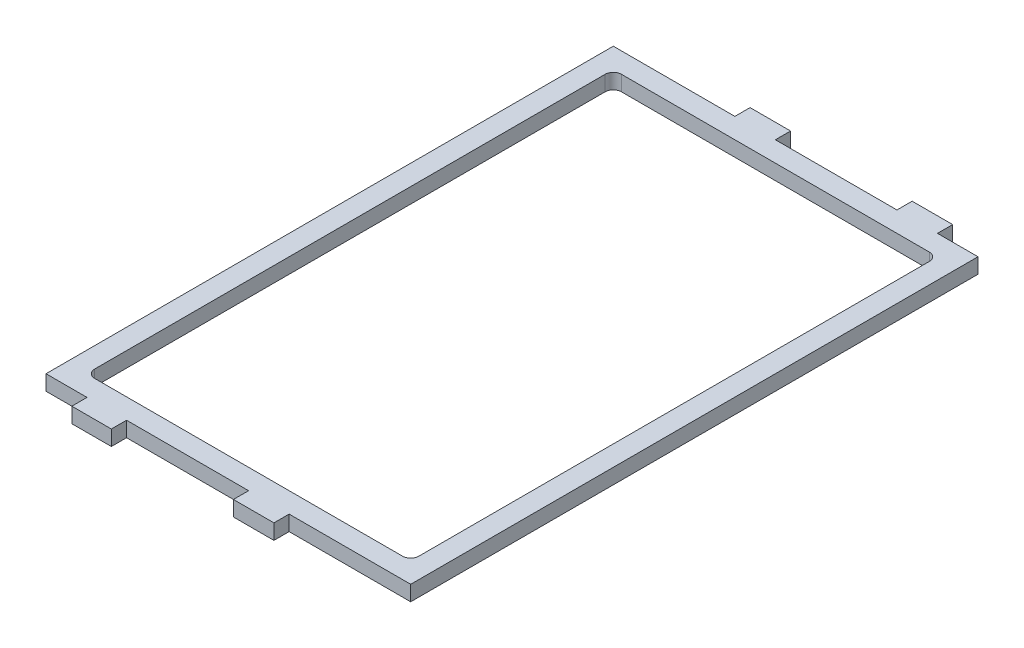
from build123d import *

# Parameters (mm, degrees)
SKETCH1_W           = 114.3
SKETCH1_H           = 177.8
SKETCH1_W_2         = 101.6
SKETCH1_H_2         = 165.1
BOSS_EXTRUDE1_DEPTH = 4.7625
SKETCH2_W           = 12.38677804
SKETCH2_H           = 4.7625
SKETCH2_W_2         = 12.7
BOSS_EXTRUDE2_DEPTH = 4.7625
SKETCH3_W           = 12.7
SKETCH3_H           = 4.7625
BOSS_EXTRUDE3_DEPTH = 4.7625
FILLET1_R           = 2.54


with BuildPart() as part:
    # Sketch1 → Boss-Extrude1 (new body)
    with BuildSketch(Plane(origin=(0, 0, 0), x_dir=(1, 0, 0), z_dir=(0, 1, 0))):
        Rectangle(SKETCH1_W, SKETCH1_H)
        Rectangle(SKETCH1_W_2, SKETCH1_H_2, mode=Mode.SUBTRACT)
    extrude(amount=BOSS_EXTRUDE1_DEPTH)

    # Sketch2 → Boss-Extrude2 (add)
    with BuildSketch(Plane.XY.offset(88.9)):
        with Locations((-38.1, 2.38125)):
            Rectangle(SKETCH2_W, SKETCH2_H)
        with Locations((12.7, 2.38125)):
            Rectangle(SKETCH2_W_2, SKETCH2_H)
    extrude(amount=BOSS_EXTRUDE2_DEPTH)

    # Sketch3 → Boss-Extrude3 (add)
    with BuildSketch(Plane(origin=(0, 0, -88.9), x_dir=(-1, 0, 0), z_dir=(0, 0, -1))):
        with Locations((-38.1, 2.38125)):
            Rectangle(SKETCH3_W, SKETCH3_H)
        with Locations((12.7, 2.38125)):
            Rectangle(SKETCH3_W, SKETCH3_H)
    extrude(amount=BOSS_EXTRUDE3_DEPTH)

    # Fillet1
    fillet1_edges = [part.edges().sort_by_distance(p)[0] for p in [
        (50.8, 2.38125, 82.55),
        (50.8, 2.38125, -82.55),
        (-50.8, 2.38125, -82.55),
        (-50.8, 2.38125, 82.55),
    ]]
    fillet(fillet1_edges, radius=FILLET1_R)


solid = part.part
